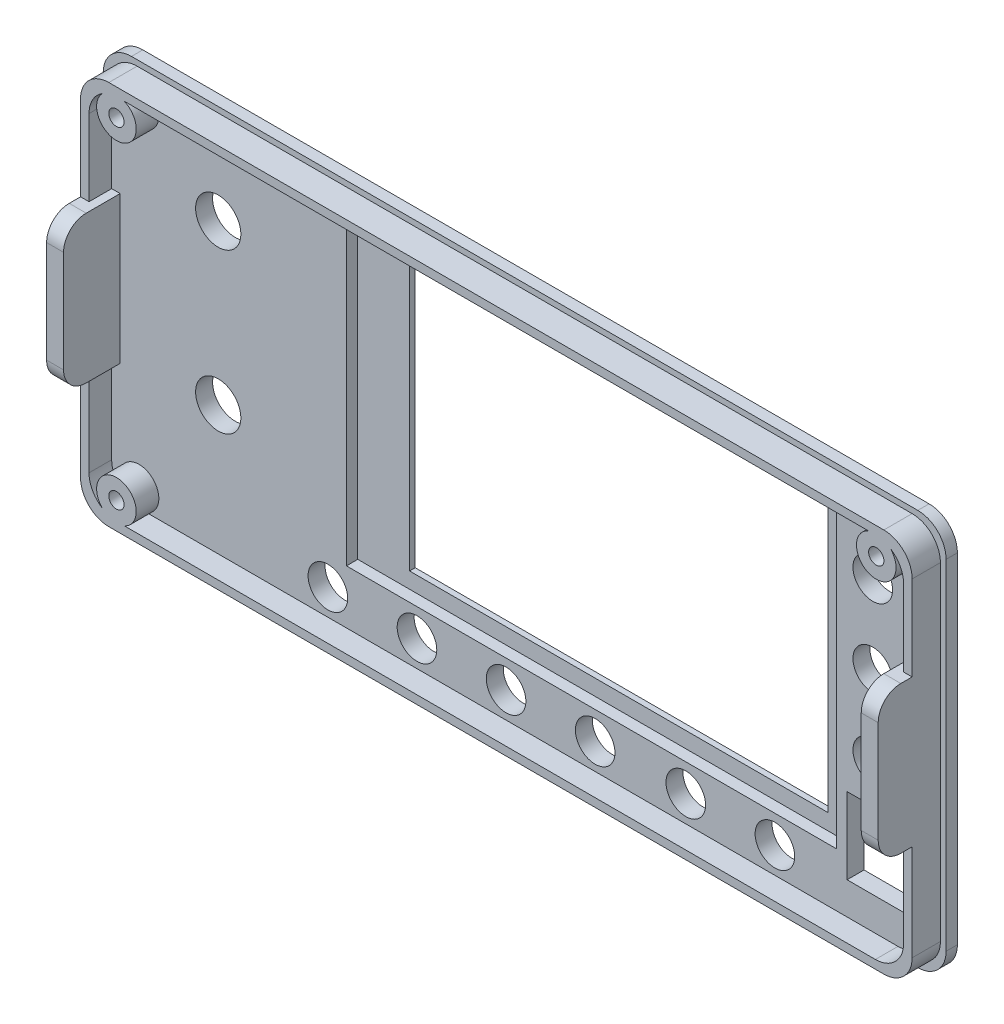
from build123d import *

# Parameters (mm, degrees)
SKETCH_1_W           = 149
SKETCH_1_H           = 70
EXTRUDE_1_DEPTH      = 1
SKETCH_2_W           = 147
SKETCH_2_H           = 68
EXTRUDE_2_DEPTH      = 2
FILLET_1_R           = 5
SKETCH_3_W           = 3
SKETCH_3_H           = 26
EXTRUDE_3_DEPTH      = 10
FILLET_2_R           = 4
SKETCH_6_R           = 3.5
EXTRUDE_4_DEPTH      = 4
SKETCH_7_W           = 86.66
SKETCH_7_H           = 55.5
CUT_EXTRUDE_3_DEPTH  = 2
SKETCH_8_W           = 74
SKETCH_8_H           = 49
CUT_EXTRUDE_4_DEPTH  = 2
SKETCH_11_R          = 4
CUT_EXTRUDE_7_DEPTH  = 4
SKETCH_12_R          = 1.35
CUT_EXTRUDE_8_DEPTH  = 4
SKETCH_13_R          = 1.35
CUT_EXTRUDE_9_DEPTH  = 4
SKETCH_14_R          = 1.35
CUT_EXTRUDE_10_DEPTH = 4
SKETCH_15_W          = 14
SKETCH_15_H          = 13.5
CUT_EXTRUDE_11_DEPTH = 4
SKETCH_9_R           = 3.5
CUT_EXTRUDE_12_DEPTH = 4
SKETCH_16_R          = 3.5
CUT_EXTRUDE_13_DEPTH = 4
EXTRUDE_5_DEPTH      = 4
EXTRUDE_6_DEPTH      = 1


with BuildPart() as part:
    # Эскиз1 → Бобышка-Вытянуть1 (new body)
    with BuildSketch(Plane.XY):
        Rectangle(SKETCH_1_W, SKETCH_1_H)
    extrude(amount=EXTRUDE_1_DEPTH)

    # Эскиз2 → Бобышка-Вытянуть2 (add)
    with BuildSketch(Plane.XY.offset(1)):
        Rectangle(SKETCH_2_W, SKETCH_2_H)
    extrude(amount=EXTRUDE_2_DEPTH)

    # Скругление1
    fillet_1_edges = [part.edges().sort_by_distance(p)[0] for p in [
        (-73.5, 34, 2),
        (-73.5, -34, 2),
        (73.5, -34, 2),
        (73.5, 34, 2),
        (-74.5, 35, 0.5),
        (74.5, 35, 0.5),
        (74.5, -35, 0.5),
        (-74.5, -35, 0.5),
    ]]
    fillet(fillet_1_edges, radius=FILLET_1_R)

    # Эскиз3 → Бобышка-Вытянуть3 (add)
    with BuildSketch(Plane.XY.offset(3)):
        with Locations((-72, 1)):
            Rectangle(SKETCH_3_W, SKETCH_3_H)
        with Locations((72, 1)):
            Rectangle(SKETCH_3_W, SKETCH_3_H)
    extrude(amount=EXTRUDE_3_DEPTH)

    # Скругление2
    fillet_2_edges = [part.edges().sort_by_distance(p)[0] for p in [
        (-72, -12, 13),
        (-72, 14, 13),
        (72, 14, 13),
        (72, -12, 13),
    ]]
    fillet(fillet_2_edges, radius=FILLET_2_R)

    # Эскиз6 → Бобышка-Вытянуть4 (add)
    with BuildSketch(Plane.XY.offset(3)):
        with Locations((-67.16, 29.285)):
            Circle(SKETCH_6_R)
        with Locations((67.16, 29.285)):
            Circle(SKETCH_6_R)
        with Locations((-67.16, -29.285)):
            Circle(SKETCH_6_R)
    extrude(amount=EXTRUDE_4_DEPTH)

    # Эскиз7 → Вырез-Вытянуть3 (cut)
    with BuildSketch(Plane.XY.offset(3)):
        with Locations((12.83, 4.75)):
            Rectangle(SKETCH_7_W, SKETCH_7_H)
    extrude(amount=-CUT_EXTRUDE_3_DEPTH, mode=Mode.SUBTRACT)

    # Эскиз8 → Вырез-Вытянуть4 (cut, through all)
    with BuildSketch(Plane.XY.offset(1)):
        with Locations((15.66, 4.3)):
            Rectangle(SKETCH_8_W, SKETCH_8_H)
    extrude(amount=-CUT_EXTRUDE_4_DEPTH, mode=Mode.SUBTRACT)

    # Эскиз11 → Вырез-Вытянуть7 (cut, through all)
    with BuildSketch(Plane.XY.offset(3)):
        with Locations((-53.163, 18.448)):
            Circle(SKETCH_11_R)
        with Locations((-53.163, -9.69)):
            Circle(SKETCH_11_R)
    extrude(amount=-CUT_EXTRUDE_7_DEPTH, mode=Mode.SUBTRACT)

    # Эскиз12 → Вырез-Вытянуть8 (cut)
    with BuildSketch(Plane.XY.offset(7)):
        with Locations((-67.16, 29.285)):
            Circle(SKETCH_12_R)
    extrude(amount=-CUT_EXTRUDE_8_DEPTH, mode=Mode.SUBTRACT)

    # Эскиз13 → Вырез-Вытянуть9 (cut)
    with BuildSketch(Plane.XY.offset(7)):
        with Locations((67.16, 29.285)):
            Circle(SKETCH_13_R)
    extrude(amount=-CUT_EXTRUDE_9_DEPTH, mode=Mode.SUBTRACT)

    # Эскиз14 → Вырез-Вытянуть10 (cut)
    with BuildSketch(Plane.XY.offset(7)):
        with Locations((-67.16, -29.285)):
            Circle(SKETCH_14_R)
    extrude(amount=-CUT_EXTRUDE_10_DEPTH, mode=Mode.SUBTRACT)

    # Эскиз15 → Вырез-Вытянуть11 (cut, through all)
    with BuildSketch(Plane.XY.offset(3)):
        with Locations((65, -20.05)):
            Rectangle(SKETCH_15_W, SKETCH_15_H)
    extrude(amount=-CUT_EXTRUDE_11_DEPTH, mode=Mode.SUBTRACT)

    # Эскиз9 → Вырез-Вытянуть12 (cut, through all)
    with BuildSketch(Plane.XY.offset(3)):
        with Locations((62.54, -6.405)):
            Circle(SKETCH_9_R)
        with Locations((62.54, 21.595)):
            Circle(SKETCH_9_R)
        with Locations((62.54, 7.595)):
            Circle(SKETCH_9_R)
    extrude(amount=-CUT_EXTRUDE_12_DEPTH, mode=Mode.SUBTRACT)

    # Эскиз16 → Вырез-Вытянуть13 (cut, through all)
    with BuildSketch(Plane.XY.offset(3)):
        with Locations((45.24, -27.88)):
            Circle(SKETCH_16_R)
        with Locations((29.49, -27.88)):
            Circle(SKETCH_16_R)
        with Locations((13.47, -27.88)):
            Circle(SKETCH_16_R)
        with Locations((-2.28, -27.88)):
            Circle(SKETCH_16_R)
        with Locations((-18.03, -27.88)):
            Circle(SKETCH_16_R)
        with Locations((-33.78, -27.88)):
            Circle(SKETCH_16_R)
    extrude(amount=-CUT_EXTRUDE_13_DEPTH, mode=Mode.SUBTRACT)

    # Эскиз17 → Бобышка-Вытянуть5 (add)
    with BuildSketch(Plane.XY.offset(3)):
        with BuildLine():
            Line((68.5, -34), (-68.5, -34))
            ThreePointArc((-68.5, -34), (-72.035533906, -32.535533906), (-73.5, -29))
            Line((-73.5, -29), (-73.5, 29))
            ThreePointArc((-73.5, 29), (-72.035533906, 32.535533906), (-68.5, 34))
            Line((-68.5, 34), (68.5, 34))
            ThreePointArc((68.5, 34), (72.035533906, 32.535533906), (73.5, 29))
            Line((73.5, 29), (73.5, -29))
            ThreePointArc((73.5, -29), (72.035533906, -32.535533906), (68.5, -34))
        make_face()
        with BuildLine():
            Line((67, -32.5), (-67, -32.5))
            ThreePointArc((-67, -32.5), (-70.535533906, -31.035533906), (-72, -27.5))
            Line((-72, -27.5), (-72, 27.5))
            ThreePointArc((-72, 27.5), (-70.535533906, 31.035533906), (-67, 32.5))
            Line((-67, 32.5), (67, 32.5))
            ThreePointArc((67, 32.5), (70.535533906, 31.035533906), (72, 27.5))
            Line((72, 27.5), (72, -27.5))
            ThreePointArc((72, -27.5), (70.535533906, -31.035533906), (67, -32.5))
        make_face(mode=Mode.SUBTRACT)
    extrude(amount=EXTRUDE_5_DEPTH)

    # Эскиз18 → Бобышка-Вытянуть6 (add)
    with BuildSketch(Plane.XY.offset(1)):
        with BuildLine():
            Line((69.5, -35), (-69.5, -35))
            ThreePointArc((-69.5, -35), (-73.035533906, -33.535533906), (-74.5, -30))
            Line((-74.5, -30), (-74.5, 30))
            ThreePointArc((-74.5, 30), (-73.035533906, 33.535533906), (-69.5, 35))
            Line((-69.5, 35), (69.5, 35))
            ThreePointArc((69.5, 35), (73.035533906, 33.535533906), (74.5, 30))
            Line((74.5, 30), (74.5, -30))
            ThreePointArc((74.5, -30), (73.035533906, -33.535533906), (69.5, -35))
        make_face()
        with BuildLine():
            Line((68.5, -34), (-68.5, -34))
            ThreePointArc((-68.5, -34), (-72.035533906, -32.535533906), (-73.5, -29))
            Line((-73.5, -29), (-73.5, 29))
            ThreePointArc((-73.5, 29), (-72.035533906, 32.535533906), (-68.5, 34))
            Line((-68.5, 34), (68.5, 34))
            ThreePointArc((68.5, 34), (72.035533906, 32.535533906), (73.5, 29))
            Line((73.5, 29), (73.5, -29))
            ThreePointArc((73.5, -29), (72.035533906, -32.535533906), (68.5, -34))
        make_face(mode=Mode.SUBTRACT)
    extrude(amount=EXTRUDE_6_DEPTH)


solid = part.part
